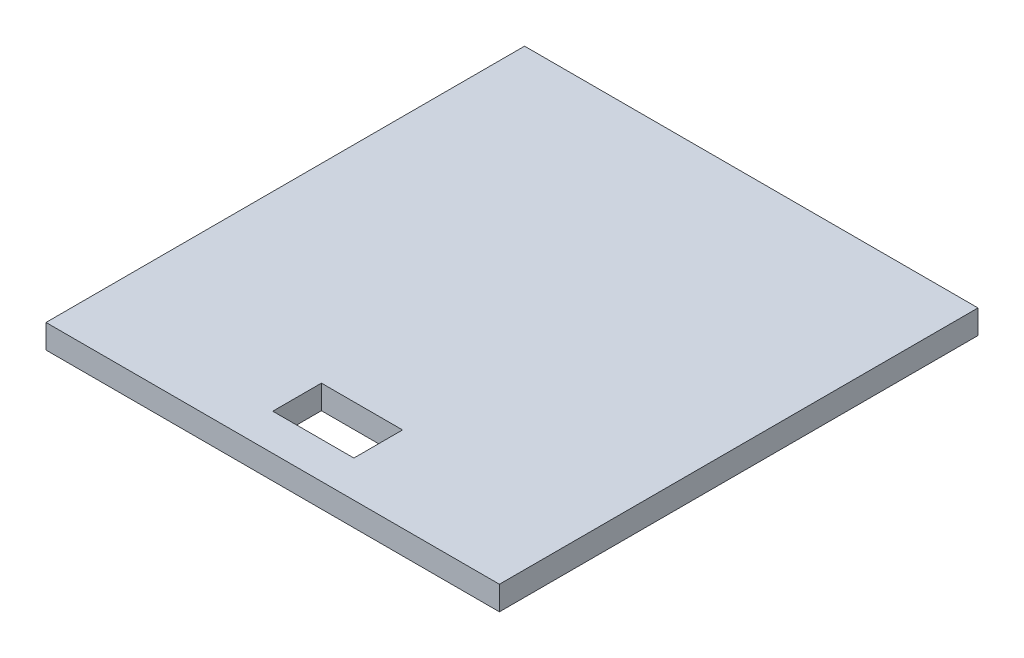
from build123d import *

# Parameters (mm, degrees)
SKETCH1_W           = 55.9
SKETCH1_H           = 59
BOSS_EXTRUDE1_DEPTH = 2.95
SKETCH4_W           = 10
SKETCH4_H           = 6
CUT_EXTRUDE2_DEPTH  = 6.86


with BuildPart() as part:
    # Sketch1 → Boss-Extrude1 (new body)
    with BuildSketch(Plane(origin=(0, 0, 0), x_dir=(1, 0, 0), z_dir=(0, 1, 0))):
        with Locations((-17.123891626, -2.775862069)):
            Rectangle(SKETCH1_W, SKETCH1_H)
    extrude(amount=BOSS_EXTRUDE1_DEPTH)

    # Sketch4 → Cut-Extrude2 (cut)
    with BuildSketch(Plane(origin=(0, 2.95, 0), x_dir=(1, 0, 0), z_dir=(0, 1, 0))):
        with Locations((-16.619002629, -24.775862069)):
            Rectangle(SKETCH4_W, SKETCH4_H)
    extrude(amount=-CUT_EXTRUDE2_DEPTH, mode=Mode.SUBTRACT)


solid = part.part
